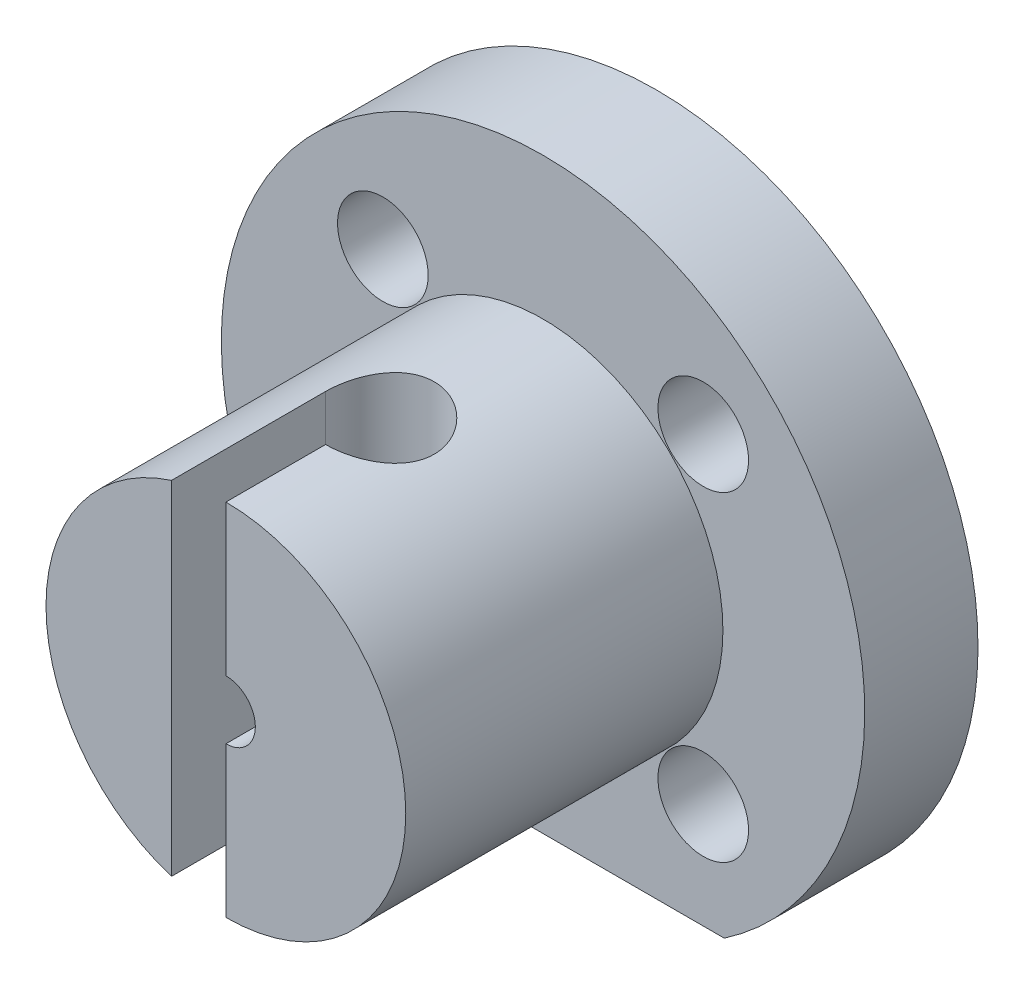
from build123d import *

# Parameters (mm, degrees)
CROQUIS1_R                 = 35.5
CROQUIS1_R_2               = 3.25
SALIENTE_EXTRUIR1_DEPTH    = 5
CROQUIS9_R                 = 19.85
CROQUIS9_R_2               = 3.25
SALIENTE_EXTRUIR4_DEPTH    = 35
CORTAR_EXTRUIR4_DEPTH      = 36.5
CORTAR_EXTRUIR4_DEPTH_BACK = 36.5
CROQUIS11_R                = 35.5
CROQUIS11_R_2              = 3.25
SALIENTE_EXTRUIR5_DEPTH    = 7.5
CROQUIS13_R                = 5
CORTAR_EXTRUIR5_DEPTH      = 7.5
CORTAR_EXTRUIR7_DEPTH      = 13.5


with BuildPart() as part:
    # Croquis1 → Saliente-Extruir1 (new body)
    with BuildSketch(Plane.XY):
        Circle(CROQUIS1_R)
        with Locations((17.67766953, 17.67766953)):
            Circle(CROQUIS1_R_2, mode=Mode.SUBTRACT)
        with Locations((17.67766953, -17.67766953)):
            Circle(CROQUIS1_R_2, mode=Mode.SUBTRACT)
        with Locations((-17.67766953, -17.67766953)):
            Circle(CROQUIS1_R_2, mode=Mode.SUBTRACT)
        with Locations((-17.67766953, 17.67766953)):
            Circle(CROQUIS1_R_2, mode=Mode.SUBTRACT)
        Circle(CROQUIS1_R_2, mode=Mode.SUBTRACT)
    extrude(amount=SALIENTE_EXTRUIR1_DEPTH)

    # Croquis9 → Saliente-Extruir4 (add)
    with BuildSketch(Plane.XY.offset(5)):
        Circle(CROQUIS9_R)
        Circle(CROQUIS9_R_2, mode=Mode.SUBTRACT)
    extrude(amount=SALIENTE_EXTRUIR4_DEPTH)

    # Croquis10 → Cortar-Extruir4 (cut, two sides)
    with BuildSketch(Plane(origin=(0, 0, 0), x_dir=(1, 0, 0), z_dir=(0, 1, 0))) as cortar_extruir4_sk:
        with BuildLine():
            Line((0, -29), (0, -40))
            Line((0, -40), (-6, -40))
            Line((-6, -40), (-6, -23))
            ThreePointArc((-6, -23), (4.242640687, -18.757359313), (0, -29))
        make_face()
    extrude(amount=CORTAR_EXTRUIR4_DEPTH, mode=Mode.SUBTRACT)
    extrude(cortar_extruir4_sk.sketch, amount=-CORTAR_EXTRUIR4_DEPTH_BACK, mode=Mode.SUBTRACT)

    # Croquis11 → Saliente-Extruir5 (add)
    with BuildSketch(Plane(origin=(0, 0, 0), x_dir=(-1, 0, 0), z_dir=(0, 0, -1))):
        Circle(CROQUIS11_R)
        with Locations((17.67766953, -17.67766953)):
            Circle(CROQUIS11_R_2, mode=Mode.SUBTRACT)
        Circle(CROQUIS11_R_2, mode=Mode.SUBTRACT)
        with Locations((-17.67766953, -17.67766953)):
            Circle(CROQUIS11_R_2, mode=Mode.SUBTRACT)
        with Locations((17.67766953, 17.67766953)):
            Circle(CROQUIS11_R_2, mode=Mode.SUBTRACT)
        with Locations((-17.67766953, 17.67766953)):
            Circle(CROQUIS11_R_2, mode=Mode.SUBTRACT)
    extrude(amount=SALIENTE_EXTRUIR5_DEPTH)

    # Croquis13 → Cortar-Extruir5 (cut)
    with BuildSketch(Plane.XY.offset(5)):
        with Locations((-17.67766953, 17.67766953)):
            Circle(CROQUIS13_R)
        with Locations((17.67766953, 17.67766953)):
            Circle(CROQUIS13_R)
        with Locations((17.67766953, -17.67766953)):
            Circle(CROQUIS13_R)
        with Locations((-17.67766953, -17.67766953)):
            Circle(CROQUIS13_R)
        with BuildLine():
            Line((-20, -29.330018752), (20, -29.330018752))
            ThreePointArc((20, -29.330018752), (0, -35.5), (-20, -29.330018752))
        make_face()
    extrude(amount=-CORTAR_EXTRUIR5_DEPTH, mode=Mode.SUBTRACT)

    # Croquis15 → Cortar-Extruir7 (cut, through all)
    with BuildSketch(Plane.XY.offset(5)):
        with BuildLine():
            Line((20, -29.330018752), (-20, -29.330018752))
            ThreePointArc((-20, -29.330018752), (0, -35.5), (20, -29.330018752))
        make_face()
    extrude(amount=-CORTAR_EXTRUIR7_DEPTH, mode=Mode.SUBTRACT)


solid = part.part
